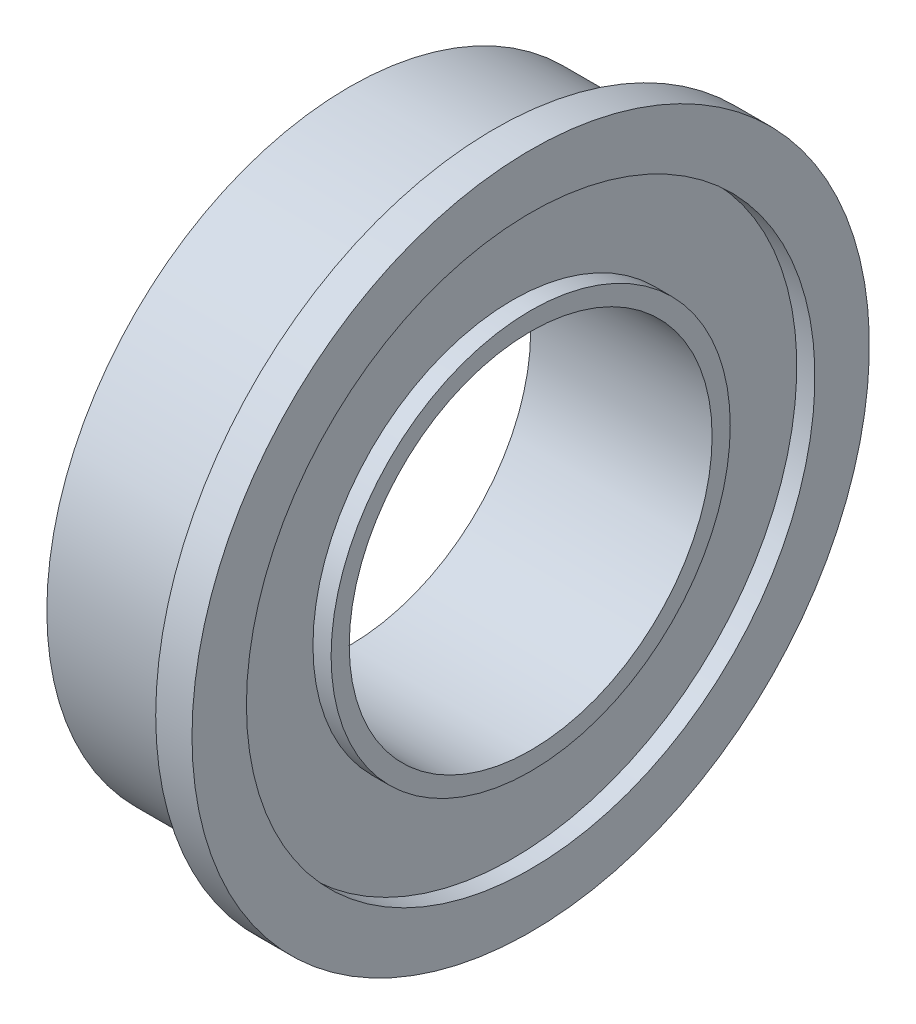
from build123d import *


with BuildPart() as part:
    # Sketch1 → Revolve1 (revolve)
    with BuildSketch(Plane.XY):
        Polygon((0, 5.6), (0, 5), (-2.4, 5), (-2.4, 4.7), (-2.1, 4.7), (-2.1, 3.3), (-2.4, 3.3), (-2.4, 3), (0.6, 3), (0.6, 3.3), (0.3, 3.3), (0.3, 4.7), (0.6, 4.7), (0.6, 5.6), align=None)
    revolve(axis=Axis((-9.631792018, 0, 0), (1, 0, 0)))


solid = part.part
